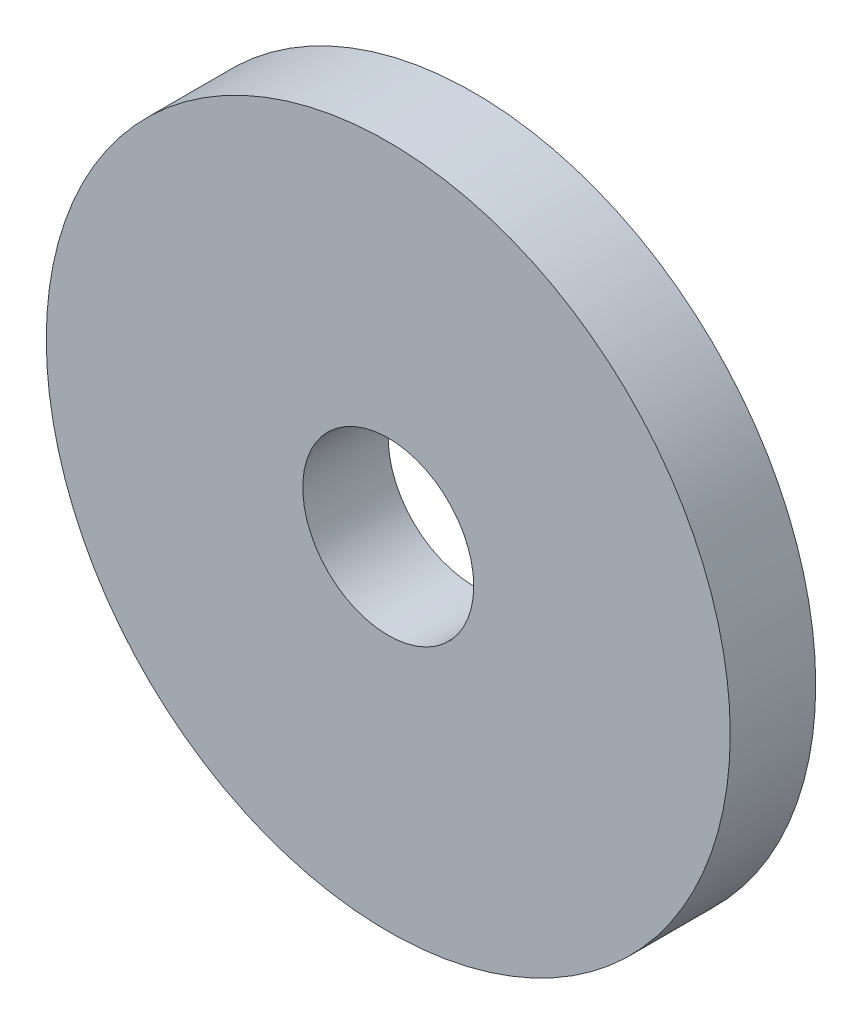
from build123d import *

# Parameters (mm, degrees)
SKETCH1_R           = 40
BOSS_EXTRUDE1_DEPTH = 10
SKETCH2_R           = 10
CUT_EXTRUDE1_DEPTH  = 11


with BuildPart() as part:
    # Sketch1 → Boss-Extrude1 (new body)
    with BuildSketch(Plane.XY):
        Circle(SKETCH1_R)
    extrude(amount=-BOSS_EXTRUDE1_DEPTH)

    # Sketch2 → Cut-Extrude1 (cut, through all)
    with BuildSketch(Plane.XY):
        Circle(SKETCH2_R)
    extrude(amount=-CUT_EXTRUDE1_DEPTH, mode=Mode.SUBTRACT)


solid = part.part
